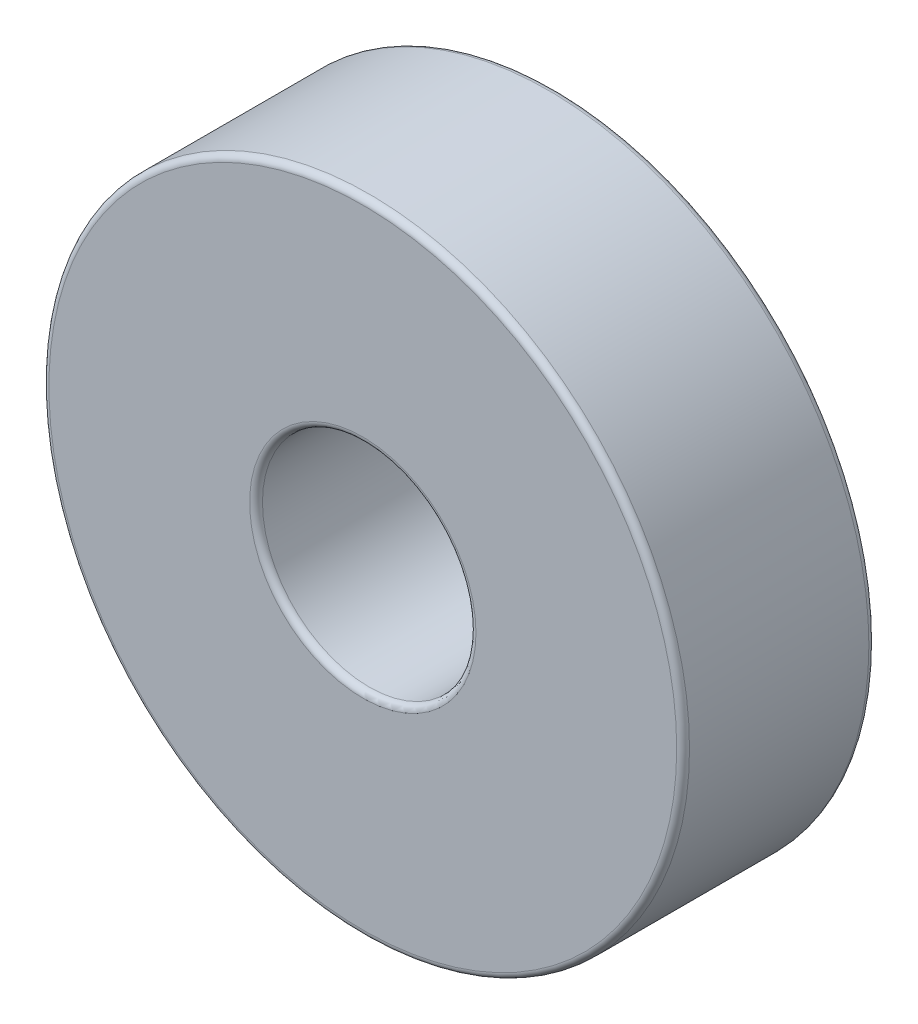
from build123d import *

# Parameters (mm, degrees)
SKETCH_1_R      = 15
SKETCH_1_R_2    = 5
EXTRUDE_1_DEPTH = 9
FILLET_1_R      = 0.3


with BuildPart() as part:
    # 草圖1 → 伸長1 (new body)
    with BuildSketch(Plane.XY):
        Circle(SKETCH_1_R)
        Circle(SKETCH_1_R_2, mode=Mode.SUBTRACT)
    extrude(amount=EXTRUDE_1_DEPTH)

    # 圓角1
    fillet_1_edges = [part.edges().sort_by_distance(p)[0] for p in [
        (-15, 0, 0),
        (-15, 0, 9),
        (-5, 0, 0),
        (-5, 0, 9),
    ]]
    fillet(fillet_1_edges, radius=FILLET_1_R)


solid = part.part
